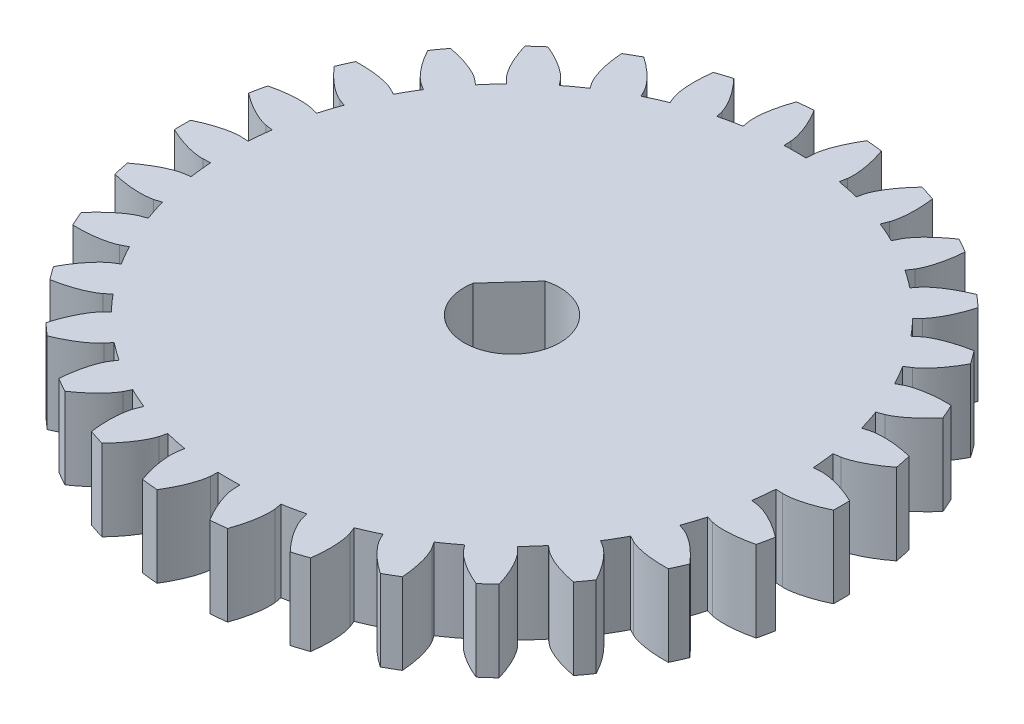
from build123d import *

# Parameters (mm, degrees)
SKETCH1_R           = 20.32
SKETCH1_R_2         = 2.95
BOSS_EXTRUDE1_DEPTH = 5
CUT_EXTRUDE1_START  = 5
CUT_EXTRUDE1_DEPTH  = 5
CIRPATTERN1_COUNT   = 30
BOSS_EXTRUDE2_DEPTH = 5


with BuildPart() as part:
    # Sketch1 → Boss-Extrude1 (new body)
    with BuildSketch(Plane(origin=(0, 0, 0), x_dir=(1, 0, 0), z_dir=(0, 1, 0))):
        Circle(SKETCH1_R)
        Circle(SKETCH1_R_2, mode=Mode.SUBTRACT)
    extrude(amount=BOSS_EXTRUDE1_DEPTH)

    # Sketch1_3 → Cut-Extrude1 (cut)
    with BuildSketch(Plane(origin=(0, 0, 0), x_dir=(1, 0, 0), z_dir=(0, 1, 0)).offset(CUT_EXTRUDE1_START)):
        with BuildLine():
            Line((-0.694982244, 17.887648572), (-0.677952602, 17.449334845))
            ThreePointArc((-0.677952602, 17.449334845), (0, 17.4625), (0.677952602, 17.449334845))
            Line((0.677952602, 17.449334845), (0.694982244, 17.887648572))
            add(Edge.make_bspline(
                [(0.694982244, 17.887648572), (0.695496162, 17.900875929), (0.697803621, 17.937931189), (0.705583554, 18.00777062), (0.723110932, 18.12117403), (0.752514436, 18.26466413), (0.798578785, 18.448621741), (0.863128671, 18.663069267), (0.944736149, 18.89596047), (1.044893832, 19.145918051), (1.154762762, 19.391945052), (1.273493453, 19.633965337), (1.399929992, 19.871796224), (1.505493526, 20.056087661), (1.580003496, 20.18025136), (1.620574569, 20.246232715), (1.625889019, 20.254848429)],
                knots=[0, 0, 0, 0, 0, 0.005376748, 0.015083688, 0.02853182, 0.046610139, 0.064854849, 0.092110525, 0.119476175, 0.146842495, 0.174208853, 0.201574955, 0.228941013, 0.256307345, 0.260421589, 0.260421589, 0.260421589, 0.260421589, 0.260421589], degree=4))
            ThreePointArc((1.625889019, 20.254848429), (0, 20.32), (-1.625889019, 20.254848429))
            add(Edge.make_bspline(
                [(-0.694982244, 17.887648572), (-0.695496162, 17.900875929), (-0.697803621, 17.937931189), (-0.705583554, 18.00777062), (-0.723110932, 18.12117403), (-0.752514436, 18.26466413), (-0.798578785, 18.448621741), (-0.863128671, 18.663069267), (-0.944736149, 18.89596047), (-1.044893832, 19.145918051), (-1.154762762, 19.391945052), (-1.273493453, 19.633965337), (-1.399929992, 19.871796224), (-1.505493526, 20.056087661), (-1.580003496, 20.18025136), (-1.620574568, 20.246232715), (-1.625889019, 20.254848429)],
                knots=[0, 0, 0, 0, 0, 0.005376748, 0.015083688, 0.02853182, 0.046610139, 0.064854849, 0.092110525, 0.119476175, 0.146842495, 0.174208853, 0.201574955, 0.228941013, 0.256307345, 0.260421589, 0.260421589, 0.260421589, 0.260421589, 0.260421589], degree=4))
        make_face()
    cut_extrude1 = extrude(amount=-CUT_EXTRUDE1_DEPTH, mode=Mode.SUBTRACT)

    # CirPattern1: Cut-Extrude1 ×30 about axis
    cirpattern1_axis = Axis((0, 5, 0), (0, -1, 0))
    for i in range(1, CIRPATTERN1_COUNT):
        add(cut_extrude1.rotate(cirpattern1_axis, i * 360 / CIRPATTERN1_COUNT), mode=Mode.SUBTRACT)

    # Sketch2 → Boss-Extrude2 (add)
    with BuildSketch(Plane(origin=(0, 5, 0), x_dir=(1, 0, 0), z_dir=(0, 1, 0))):
        with BuildLine():
            ThreePointArc((-0.808318787, 2.837097238), (-2.191125994, 1.975213123), (-2.905454084, 0.510721614))
            Line((-2.905454084, 0.510721614), (-0.808318787, 2.837097238))
        make_face()
    extrude(amount=-BOSS_EXTRUDE2_DEPTH)


solid = part.part
